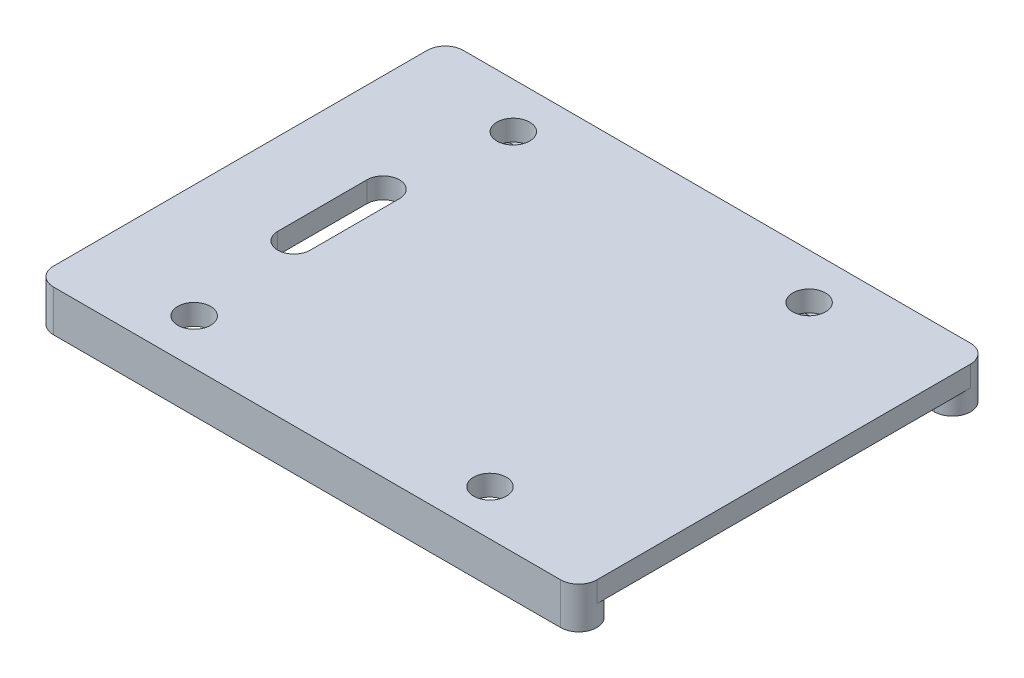
from build123d import *

# Parameters (mm, degrees)
SALIENTE_EXTRUIR1_DEPTH   = 2
SALIENTE_EXTRUIR1_2_DEPTH = 2
SALIENTE_EXTRUIR2_DEPTH   = 2
CROQUIS4_R                = 1.5875
CORTAR_EXTRUIR1_DEPTH     = 2


with BuildPart() as part:
    # Croquis2 → Saliente-Extruir1 (new body)
    with BuildSketch(Plane(origin=(0, 19.076482476, 0), x_dir=(1, 0, 0), z_dir=(0, 1, 0))):
        with BuildLine():
            Line((-22.996964511, 5.644085043), (26.003035489, 5.644085043))
            ThreePointArc((26.003035489, 5.644085043), (27.74632721, 3.900793322), (26.003035489, 2.157501601))
            Line((26.003035489, 2.157501601), (-22.996964511, 2.157501601))
            ThreePointArc((-22.996964511, 2.157501601), (-24.740256232, 3.900793322), (-22.996964511, 5.644085043))
        make_face()
    extrude(amount=-SALIENTE_EXTRUIR1_DEPTH)



with BuildPart() as body_2:
    # Croquis2 → Saliente-Extruir1 2 (new body)
    with BuildSketch(Plane(origin=(0, 19.076482476, 0), x_dir=(1, 0, 0), z_dir=(0, 1, 0))):
        with BuildLine():
            Line((-22.996964511, -33.943291721), (26.003035489, -33.943291721))
            ThreePointArc((26.003035489, -33.943291721), (27.74632721, -32.2), (26.003035489, -30.456708279))
            Line((26.003035489, -30.456708279), (-22.996964511, -30.456708279))
            ThreePointArc((-22.996964511, -30.456708279), (-24.740256232, -32.2), (-22.996964511, -33.943291721))
        make_face()
    extrude(amount=-SALIENTE_EXTRUIR1_2_DEPTH)


with BuildPart() as part_1:
    add(part.part)

    add(body_2.part)  # Saliente-Extruir2 merges body 2
    # Croquis3 → Saliente-Extruir2 (add)
    with BuildSketch(Plane(origin=(0, 19.076482476, 0), x_dir=(1, 0, 0), z_dir=(0, 1, 0))):
        with BuildLine():
            ThreePointArc((-24.740256232, 3.900793322), (-24.229657908, 2.668099924), (-22.996964511, 2.157501601))
            Line((-22.996964511, 2.157501601), (26.003035489, 2.157501601))
            ThreePointArc((26.003035489, 2.157501601), (27.235728887, 2.668099924), (27.74632721, 3.900793322))
            ThreePointArc((27.74632721, 3.900793322), (27.235728887, 5.133486719), (26.003035489, 5.644085043))
            Line((26.003035489, 5.644085043), (-22.996964511, 5.644085043))
            ThreePointArc((-22.996964511, 5.644085043), (-24.229657908, 5.133486719), (-24.740256232, 3.900793322))
        make_face()
        with BuildLine():
            Line((26.003035489, 2.157501601), (-22.996964511, 2.157501601))
            ThreePointArc((-22.996964511, 2.157501601), (-24.229657908, 2.668099924), (-24.740256232, 3.900793322))
            Line((-24.740256232, 3.900793322), (-24.740256232, -32.2))
            ThreePointArc((-24.740256232, -32.2), (-24.229657908, -30.967306602), (-22.996964511, -30.456708279))
            Line((-22.996964511, -30.456708279), (26.003035489, -30.456708279))
            ThreePointArc((26.003035489, -30.456708279), (27.235728887, -30.967306602), (27.74632721, -32.2))
            Line((27.74632721, -32.2), (27.74632721, 3.900793322))
            ThreePointArc((27.74632721, 3.900793322), (27.235728887, 2.668099924), (26.003035489, 2.157501601))
        make_face()
        with BuildLine():
            Line((-16.821172495, -18.46), (-16.821172495, -9.84))
            ThreePointArc((-16.821172495, -9.84), (-15.246964511, -8.265792016), (-13.672756527, -9.84))
            Line((-13.672756527, -9.84), (-13.672756527, -18.46))
            ThreePointArc((-13.672756527, -18.46), (-15.246964511, -20.034207984), (-16.821172495, -18.46))
        make_face(mode=Mode.SUBTRACT)
        with BuildLine():
            ThreePointArc((-22.996964511, -30.456708279), (-24.229657908, -30.967306602), (-24.740256232, -32.2))
            ThreePointArc((-24.740256232, -32.2), (-24.229657908, -33.432693398), (-22.996964511, -33.943291721))
            Line((-22.996964511, -33.943291721), (26.003035489, -33.943291721))
            ThreePointArc((26.003035489, -33.943291721), (27.235728887, -33.432693398), (27.74632721, -32.2))
            ThreePointArc((27.74632721, -32.2), (27.235728887, -30.967306602), (26.003035489, -30.456708279))
            Line((26.003035489, -30.456708279), (-22.996964511, -30.456708279))
        make_face()
    extrude(amount=SALIENTE_EXTRUIR2_DEPTH)

    # Croquis4 → Cortar-Extruir1 (cut)
    with BuildSketch(Plane(origin=(0, 21.076482476, 0), x_dir=(1, 0, 0), z_dir=(0, 1, 0))):
        with Locations((-13.784464511, 1.2625)):
            Circle(CROQUIS4_R)
        with Locations((14.790535489, 1.2625)):
            Circle(CROQUIS4_R)
        with Locations((14.790535489, -29.5625)):
            Circle(CROQUIS4_R)
        with Locations((-13.784464511, -29.5625)):
            Circle(CROQUIS4_R)
    extrude(amount=-CORTAR_EXTRUIR1_DEPTH, mode=Mode.SUBTRACT)


solid = part_1.part
